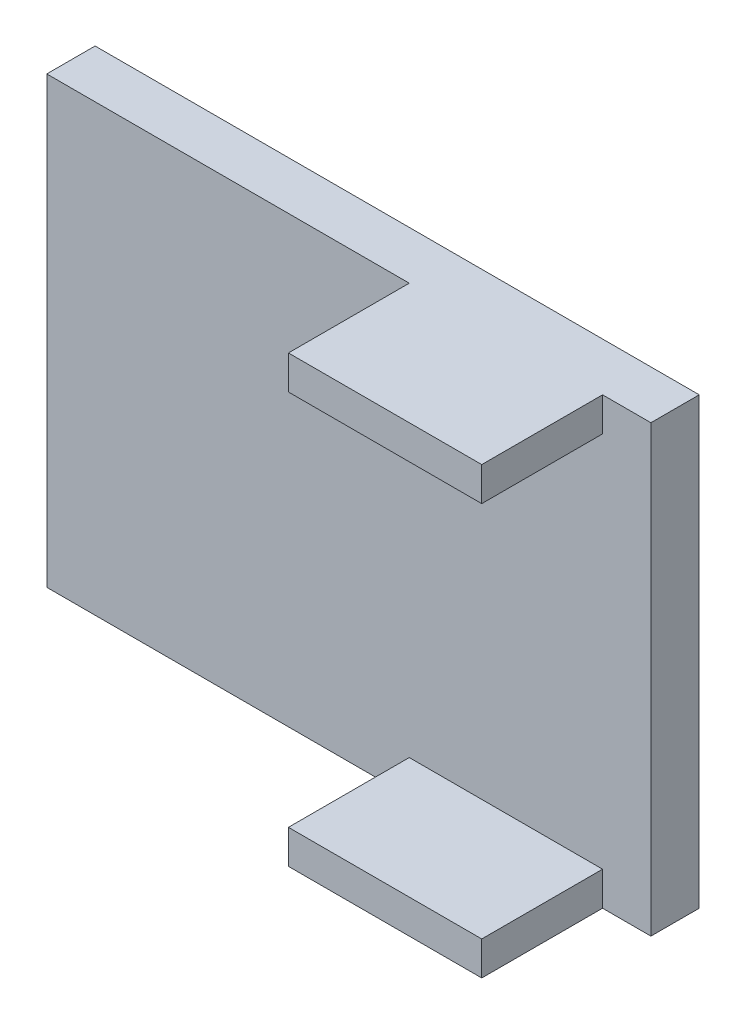
from build123d import *

# Parameters (mm, degrees)
SKETCH2_W           = 31.75
SKETCH2_H           = 23.368
BOSS_EXTRUDE1_DEPTH = 2.54
SKETCH3_W           = 12.7
SKETCH3_H           = 1.778
BOSS_EXTRUDE2_DEPTH = 6.35
SKETCH4_W           = 2.54
SKETCH4_H           = 6.35
CUT_EXTRUDE1_DEPTH  = 24.368


with BuildPart() as part:
    # Sketch2 → Boss-Extrude1 (new body)
    with BuildSketch(Plane.XY):
        Rectangle(SKETCH2_W, SKETCH2_H)
    extrude(amount=BOSS_EXTRUDE1_DEPTH)

    # Sketch3 → Boss-Extrude2 (add)
    with BuildSketch(Plane.XY.offset(2.54)):
        with Locations((9.525, 10.795)):
            Rectangle(SKETCH3_W, SKETCH3_H)
        with Locations((9.525, -10.795)):
            Rectangle(SKETCH3_W, SKETCH3_H)
    extrude(amount=BOSS_EXTRUDE2_DEPTH)

    # Sketch4 → Cut-Extrude1 (cut, through all)
    with BuildSketch(Plane(origin=(0, 11.684, 0), x_dir=(1, 0, 0), z_dir=(0, 1, 0))):
        with Locations((14.605, -5.715)):
            Rectangle(SKETCH4_W, SKETCH4_H)
    extrude(amount=-CUT_EXTRUDE1_DEPTH, mode=Mode.SUBTRACT)


solid = part.part
